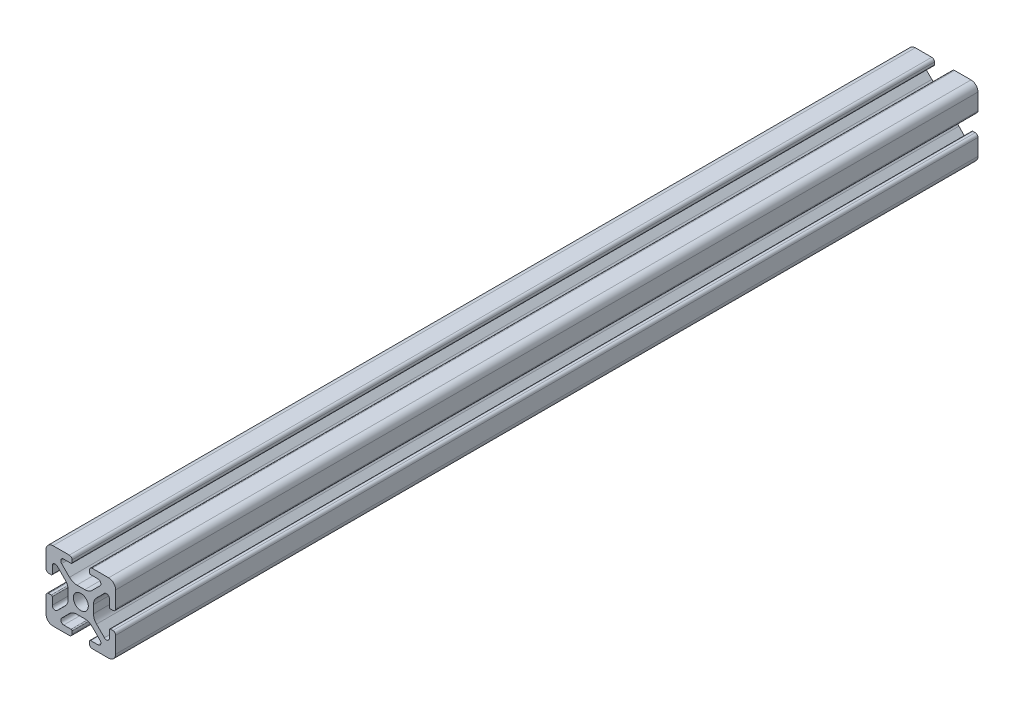
from build123d import *

# Parameters (mm, degrees)
SKETCH1_R           = 2.1463
BOSS_EXTRUDE1_DEPTH = 187.5
SKETCH2_W           = 61.526977309
SKETCH2_H           = 152.756633319
CUT_EXTRUDE1_DEPTH  = 20.9898


with BuildPart() as part:
    # Sketch1 → Boss-Extrude1 (new body, symmetric)
    with BuildSketch(Plane.XY):
        with BuildLine():
            Line((-9.9949, 7.9883), (-9.9949, 3.2893))
            ThreePointArc((-9.9949, 3.2893), (-9.76427588, 2.73252412), (-9.2075, 2.5019))
            Line((-9.2075, 2.5019), (-8.4963, 2.5019))
            ThreePointArc((-8.4963, 2.5019), (-8.280773853, 2.591173853), (-8.1915, 2.8067))
            Line((-8.1915, 2.8067), (-8.1915, 4.9149))
            ThreePointArc((-8.1915, 4.9149), (-7.674065253, 5.689295824), (-6.760603096, 5.507596904))
            Line((-6.760603096, 5.507596904), (-4.505765747, 3.252759555))
            ThreePointArc((-4.505765747, 3.252759555), (-3.856054457, 2.280397894), (-3.627906192, 1.133419111))
            Line((-3.627906192, 1.133419111), (-3.627906192, -1.133419111))
            ThreePointArc((-3.627906192, -1.133419111), (-3.856054457, -2.280397894), (-4.505765747, -3.252759555))
            Line((-4.505765747, -3.252759555), (-6.760603096, -5.507596904))
            ThreePointArc((-6.760603096, -5.507596904), (-7.674065253, -5.689295824), (-8.1915, -4.9149))
            Line((-8.1915, -4.9149), (-8.1915, -2.8067))
            ThreePointArc((-8.1915, -2.8067), (-8.280773853, -2.591173853), (-8.4963, -2.5019))
            Line((-8.4963, -2.5019), (-9.2075, -2.5019))
            ThreePointArc((-9.2075, -2.5019), (-9.76427588, -2.73252412), (-9.9949, -3.2893))
            Line((-9.9949, -3.2893), (-9.9949, -7.9883))
            ThreePointArc((-9.9949, -7.9883), (-9.407180467, -9.407180467), (-7.9883, -9.9949))
            Line((-7.9883, -9.9949), (-3.2893, -9.9949))
            ThreePointArc((-3.2893, -9.9949), (-2.73252412, -9.76427588), (-2.5019, -9.2075))
            Line((-2.5019, -9.2075), (-2.5019, -8.4963))
            ThreePointArc((-2.5019, -8.4963), (-2.591173853, -8.280773853), (-2.8067, -8.1915))
            Line((-2.8067, -8.1915), (-4.9149, -8.1915))
            ThreePointArc((-4.9149, -8.1915), (-5.689295824, -7.674065253), (-5.507596904, -6.760603096))
            Line((-5.507596904, -6.760603096), (-3.252759555, -4.505765747))
            ThreePointArc((-3.252759555, -4.505765747), (-2.280397894, -3.856054457), (-1.133419111, -3.627906192))
            Line((-1.133419111, -3.627906192), (1.133419111, -3.627906192))
            ThreePointArc((1.133419111, -3.627906192), (2.280397894, -3.856054457), (3.252759555, -4.505765747))
            Line((3.252759555, -4.505765747), (5.507596904, -6.760603096))
            ThreePointArc((5.507596904, -6.760603096), (5.689295824, -7.674065253), (4.9149, -8.1915))
            Line((4.9149, -8.1915), (2.8067, -8.1915))
            ThreePointArc((2.8067, -8.1915), (2.591173853, -8.280773853), (2.5019, -8.4963))
            Line((2.5019, -8.4963), (2.5019, -9.2075))
            ThreePointArc((2.5019, -9.2075), (2.73252412, -9.76427588), (3.2893, -9.9949))
            Line((3.2893, -9.9949), (7.9883, -9.9949))
            ThreePointArc((7.9883, -9.9949), (9.407180467, -9.407180467), (9.9949, -7.9883))
            Line((9.9949, -7.9883), (9.9949, -3.2893))
            ThreePointArc((9.9949, -3.2893), (9.76427588, -2.73252412), (9.2075, -2.5019))
            Line((9.2075, -2.5019), (8.4963, -2.5019))
            ThreePointArc((8.4963, -2.5019), (8.280773853, -2.591173853), (8.1915, -2.8067))
            Line((8.1915, -2.8067), (8.1915, -4.9149))
            ThreePointArc((8.1915, -4.9149), (7.674065253, -5.689295824), (6.760603096, -5.507596904))
            Line((6.760603096, -5.507596904), (4.505765747, -3.252759555))
            ThreePointArc((4.505765747, -3.252759555), (3.856054457, -2.280397894), (3.627906192, -1.133419111))
            Line((3.627906192, -1.133419111), (3.627906192, 1.133419111))
            ThreePointArc((3.627906192, 1.133419111), (3.856054457, 2.280397894), (4.505765747, 3.252759555))
            Line((4.505765747, 3.252759555), (6.760603096, 5.507596904))
            ThreePointArc((6.760603096, 5.507596904), (7.674065253, 5.689295824), (8.1915, 4.9149))
            Line((8.1915, 4.9149), (8.1915, 2.8067))
            ThreePointArc((8.1915, 2.8067), (8.280773853, 2.591173853), (8.4963, 2.5019))
            Line((8.4963, 2.5019), (9.2075, 2.5019))
            ThreePointArc((9.2075, 2.5019), (9.76427588, 2.73252412), (9.9949, 3.2893))
            Line((9.9949, 3.2893), (9.9949, 7.9883))
            ThreePointArc((9.9949, 7.9883), (9.407180467, 9.407180467), (7.9883, 9.9949))
            Line((7.9883, 9.9949), (3.2893, 9.9949))
            ThreePointArc((3.2893, 9.9949), (2.73252412, 9.76427588), (2.5019, 9.2075))
            Line((2.5019, 9.2075), (2.5019, 8.4963))
            ThreePointArc((2.5019, 8.4963), (2.591173853, 8.280773853), (2.8067, 8.1915))
            Line((2.8067, 8.1915), (4.9149, 8.1915))
            ThreePointArc((4.9149, 8.1915), (5.689295824, 7.674065253), (5.507596904, 6.760603096))
            Line((5.507596904, 6.760603096), (3.252759555, 4.505765747))
            ThreePointArc((3.252759555, 4.505765747), (2.280397894, 3.856054457), (1.133419111, 3.627906192))
            Line((1.133419111, 3.627906192), (-1.133419111, 3.627906192))
            ThreePointArc((-1.133419111, 3.627906192), (-2.280397894, 3.856054457), (-3.252759555, 4.505765747))
            Line((-3.252759555, 4.505765747), (-5.507596904, 6.760603096))
            ThreePointArc((-5.507596904, 6.760603096), (-5.689295824, 7.674065253), (-4.9149, 8.1915))
            Line((-4.9149, 8.1915), (-2.8067, 8.1915))
            ThreePointArc((-2.8067, 8.1915), (-2.591173853, 8.280773853), (-2.5019, 8.4963))
            Line((-2.5019, 8.4963), (-2.5019, 9.2075))
            ThreePointArc((-2.5019, 9.2075), (-2.73252412, 9.76427588), (-3.2893, 9.9949))
            Line((-3.2893, 9.9949), (-7.9883, 9.9949))
            ThreePointArc((-7.9883, 9.9949), (-9.407180467, 9.407180467), (-9.9949, 7.9883))
        make_face()
        Circle(SKETCH1_R, mode=Mode.SUBTRACT)
    extrude(amount=BOSS_EXTRUDE1_DEPTH, both=True)

    # Sketch2 → Cut-Extrude1 (cut, through all)
    with BuildSketch(Plane(origin=(0, 9.9949, 0), x_dir=(1, 0, 0), z_dir=(0, 1, 0))):
        with Locations((5.480851427, 136.37831666)):
            Rectangle(SKETCH2_W, SKETCH2_H)
    extrude(amount=-CUT_EXTRUDE1_DEPTH, mode=Mode.SUBTRACT)


solid = part.part
